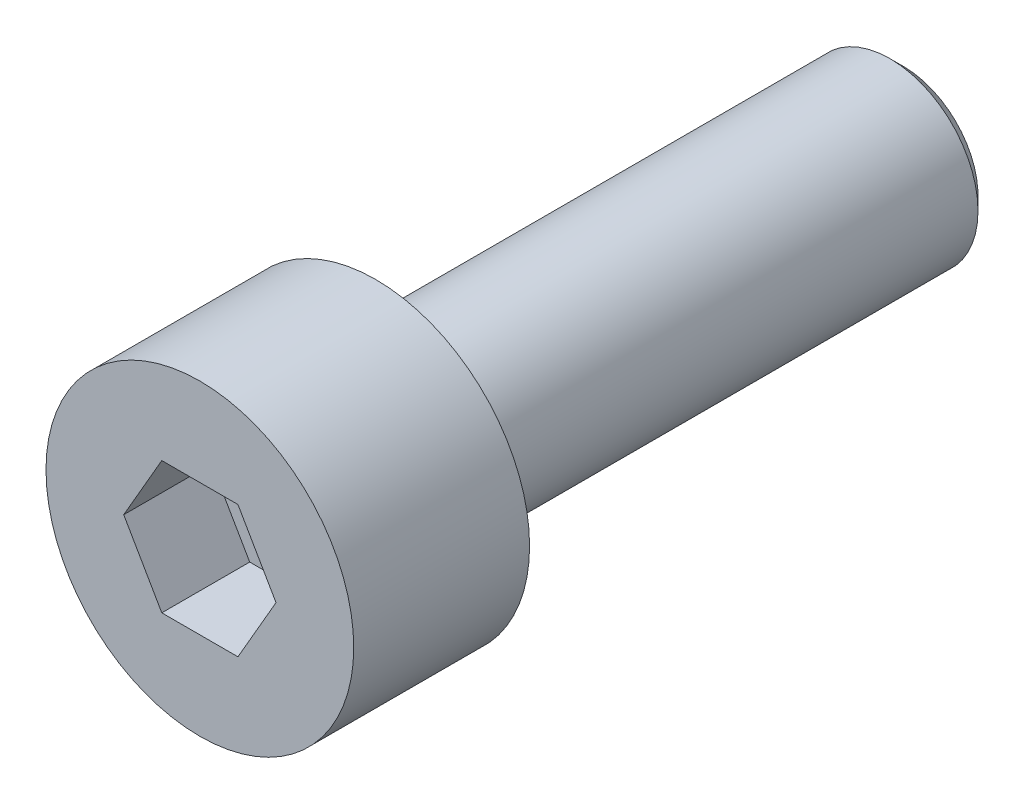
from build123d import *

# Parameters (mm, degrees)
CUT_EXTRUDE_1_DEPTH = 2
FILLET_1_R          = 0.3
CHAMFER_1_SIZE      = 0.3


with BuildPart() as part:
    # Эскиз1 → Повернуть1 (revolve)
    with BuildSketch(Plane(origin=(0, 0, 0), x_dir=(0, 0, -1), z_dir=(1, 0, 0))):
        Polygon((0, 0), (0, 3.5), (4, 3.5), (4, 2), (16, 2), (16, 0), align=None)
    revolve(axis=Axis((0, 0, 0), (0, 0, 1)))

    # Эскиз2 → Вырез-Вытянуть1 (cut)
    with BuildSketch(Plane.XY):
        Polygon((1.732050808, 0), (0.866025404, 1.5), (-0.866025404, 1.5), (-1.732050808, 0), (-0.866025404, -1.5), (0.866025404, -1.5), align=None)
    extrude(amount=-CUT_EXTRUDE_1_DEPTH, mode=Mode.SUBTRACT)

    # Скругление1
    fillet_1_edges = [part.edges().sort_by_distance(p)[0] for p in [
        (0, -2, -4),
    ]]
    fillet(fillet_1_edges, radius=FILLET_1_R)

    # Фаска1
    chamfer_1_edges = [part.edges().sort_by_distance(p)[0] for p in [
        (0, -2, -16),
    ]]
    chamfer(chamfer_1_edges, length=CHAMFER_1_SIZE)


solid = part.part
